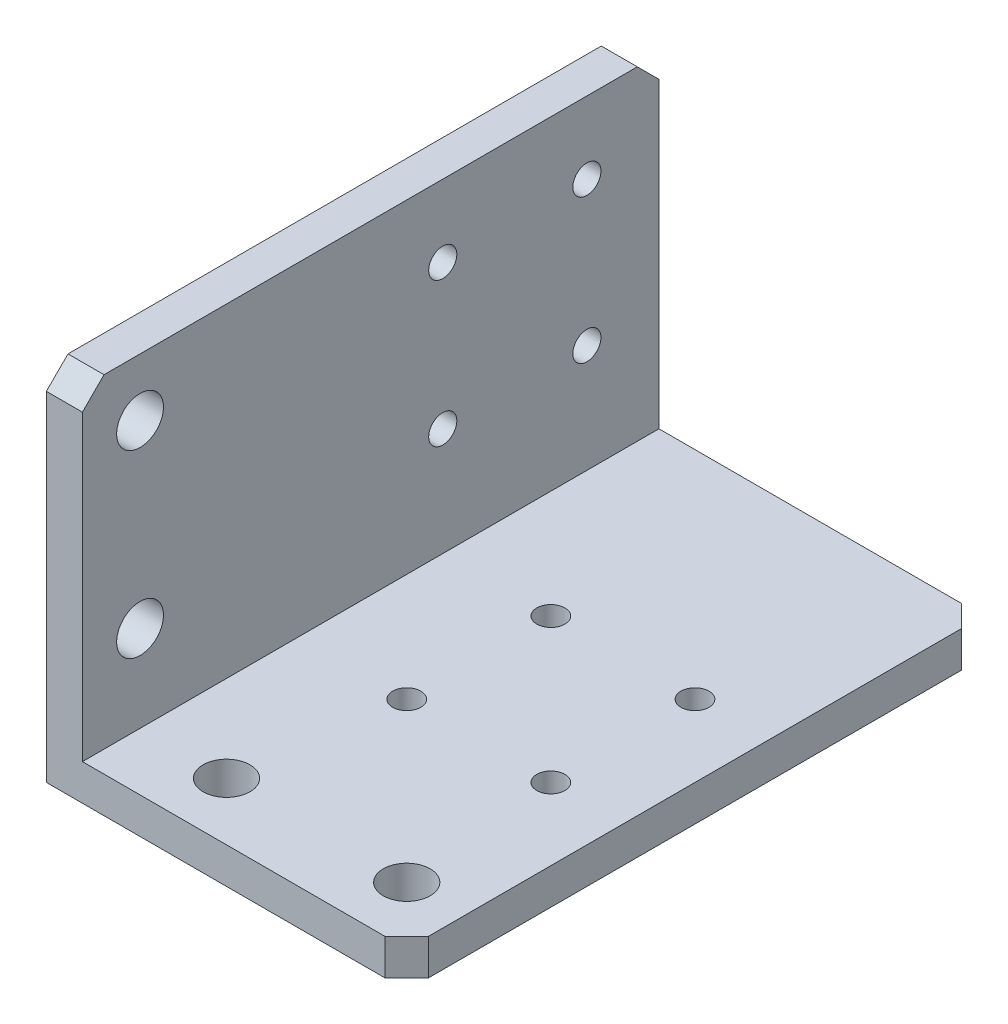
from build123d import *

# Parameters (mm, degrees)
ESTRUSIONE_ESTRUSIONE1_DEPTH = 80
FORO_6_5_6_5_1_D             = 6.5
FORO_6_5_6_5_2_D             = 6.5
FORO_6_5_6_5_2_DEPTH         = 5
FORO_6_5_6_5_2_TIP           = 1.952797012
SMUSSO1_SIZE                 = 3
M3_5_CLEARANCE_HOLE1_D       = 3.9
M3_5_CLEARANCE_HOLE2_D       = 3.9


with BuildPart() as part:
    # Schizzo1 → Estrusione-Estrusione1 (new body)
    with BuildSketch(Plane.XY):
        Polygon((0, 0), (0, 50), (5, 50), (5, 5), (50, 5), (50, 0), align=None)
    extrude(amount=ESTRUSIONE_ESTRUSIONE1_DEPTH)

    # Foro Ø6.5 (6.5)-1 (through all)
    with Locations(Plane(origin=(0, 0, 0), x_dir=(-1, 0, 0), z_dir=(0, -1, 0))):
        with Locations((-17, -72), (-42, -72)):
            Hole(FORO_6_5_6_5_1_D / 2)

    # Foro Ø6.5 (6.5)-2
    with Locations(Plane.ZY):
        with Locations((72, 42), (72, 17)):
            Hole(FORO_6_5_6_5_2_D / 2, depth=FORO_6_5_6_5_2_DEPTH)
            with Locations((0, 0, -(FORO_6_5_6_5_2_DEPTH + FORO_6_5_6_5_2_TIP / 2))):  # 118° drill point
                Cone(0, FORO_6_5_6_5_2_D / 2, FORO_6_5_6_5_2_TIP, mode=Mode.SUBTRACT)

    # Smusso1
    smusso1_edges = [part.edges().sort_by_distance(p)[0] for p in [
        (2.5, 50, 80),
        (2.5, 50, 0),
        (50, 2.5, 80),
        (50, 2.5, 0),
    ]]
    chamfer(smusso1_edges, length=SMUSSO1_SIZE)

    # M3.5 Clearance Hole1 (through all)
    with Locations(Plane(origin=(0, 40, 10), x_dir=(0, 0, -1), z_dir=(-1, 0, 0))):
        with Locations((0, 0), (-20, 0), (-20, 20), (0, 20)):
            Hole(M3_5_CLEARANCE_HOLE1_D / 2)

    # M3.5 Clearance Hole2 (through all)
    with Locations(Plane(origin=(20, 0, 50), x_dir=(-1, 0, 0), z_dir=(0, -1, 0))):
        with Locations((0, 0), (-20, 0), (-20, 20), (0, 20)):
            Hole(M3_5_CLEARANCE_HOLE2_D / 2)


solid = part.part
